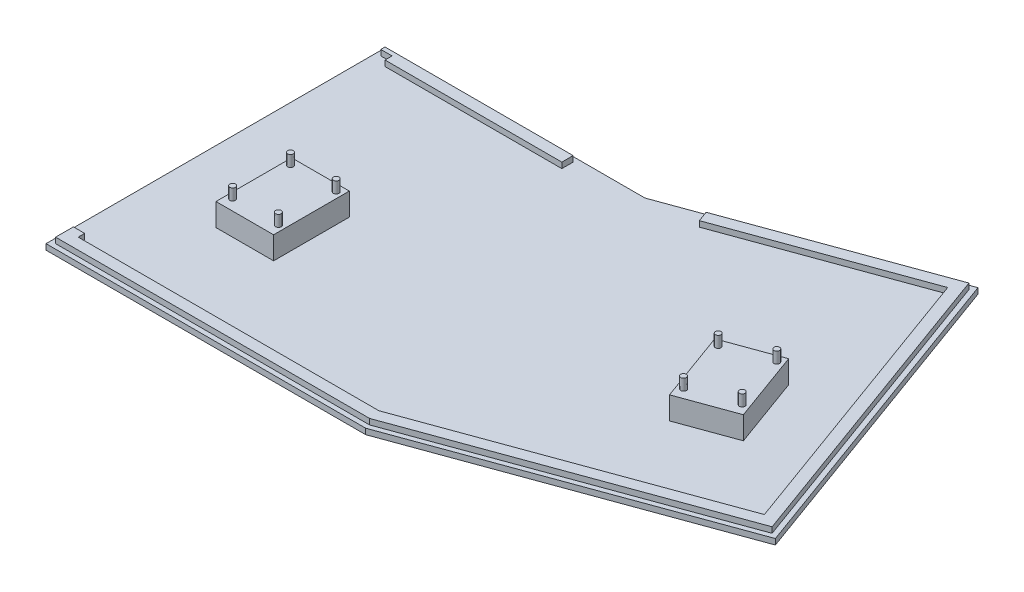
from build123d import *

# Parameters (mm, degrees)
BOSS_EXTRUDE1_DEPTH = 2.54
BOSS_EXTRUDE2_DEPTH = 2.54
SKETCH5_W           = 25.908
SKETCH5_H           = 34.036
BOSS_EXTRUDE3_DEPTH = 12.7
SKETCH6_R           = 1.27
BOSS_EXTRUDE4_DEPTH = 5.08
SKETCH7_W           = 5.08
SKETCH7_H           = 138.176
CUT_EXTRUDE1_DEPTH  = 2.54
CUT_EXTRUDE2_DEPTH  = 2.54


with BuildPart() as part:
    # Sketch1 → Boss-Extrude1 (new body)
    with BuildSketch(Plane(origin=(0, 0, 0), x_dir=(1, 0, 0), z_dir=(0, 1, 0))):
        Polygon((0, 0), (0, 152.4), (116.84, 152.4), (143.709327723, 0.01647018), align=None)
    extrude(amount=BOSS_EXTRUDE1_DEPTH)

    # Sketch2 → Boss-Extrude2 (add)
    with BuildSketch(Plane(origin=(0, 2.54, 0), x_dir=(1, 0, 0), z_dir=(0, 1, 0))):
        Polygon((117.220689951, 150.241), (2.159, 150.241), (2.159, 2.159), (143.331541909, 2.159), (142.435800847, 7.239), (7.239, 7.239), (7.239, 145.161), (118.116431013, 145.161), align=None)
    extrude(amount=BOSS_EXTRUDE2_DEPTH)

    # Sketch5 → Boss-Extrude3 (add)
    with BuildSketch(Plane.XZ):
        with Locations((44.90593, -61.477652)):
            Rectangle(SKETCH5_W, SKETCH5_H)
    extrude(amount=-BOSS_EXTRUDE3_DEPTH)

    # Sketch6 → Boss-Extrude4 (add)
    with BuildSketch(Plane(origin=(0, 12.7, 0), x_dir=(1, 0, 0), z_dir=(0, 1, 0))):
        with Locations((34.625191146, 75.319771658)):
            Circle(SKETCH6_R)
        with Locations((55.169983581, 75.290564093)):
            Circle(SKETCH6_R)
        with Locations((55.199191146, 49.284771658)):
            Circle(SKETCH6_R)
        with Locations((34.625191146, 49.284771658)):
            Circle(SKETCH6_R)
    extrude(amount=BOSS_EXTRUDE4_DEPTH)

    # Mirror2: part across plane


with BuildPart() as part_1:
    add(part.part)
    add(part.part.mirror(Plane(origin=(116.84, 2.54, -152.4), x_dir=(0.173648178, 0, 0.984807753), z_dir=(0.984807753, 0, -0.173648178))))

    # Sketch7 → Cut-Extrude1 (cut)
    with BuildSketch(Plane(origin=(0, 5.08, 0), x_dir=(1, 0, 0), z_dir=(0, 1, 0))):
        with Locations((4.699, 79.248)):
            Rectangle(SKETCH7_W, SKETCH7_H)
    extrude(amount=-CUT_EXTRUDE1_DEPTH, mode=Mode.SUBTRACT)

    # Sketch8 → Cut-Extrude2 (cut)
    with BuildSketch(Plane(origin=(0, 5.08, 0), x_dir=(1, 0, 0), z_dir=(0, 1, 0))):
        Polygon((86.740689951, 150.241), (86.740689951, 145.161), (118.116431013, 145.161), (140.439525591, 153.285941963), (138.702063263, 158.059580476), (117.220689951, 150.241), align=None)
    extrude(amount=-CUT_EXTRUDE2_DEPTH, mode=Mode.SUBTRACT)


solid = part_1.part
